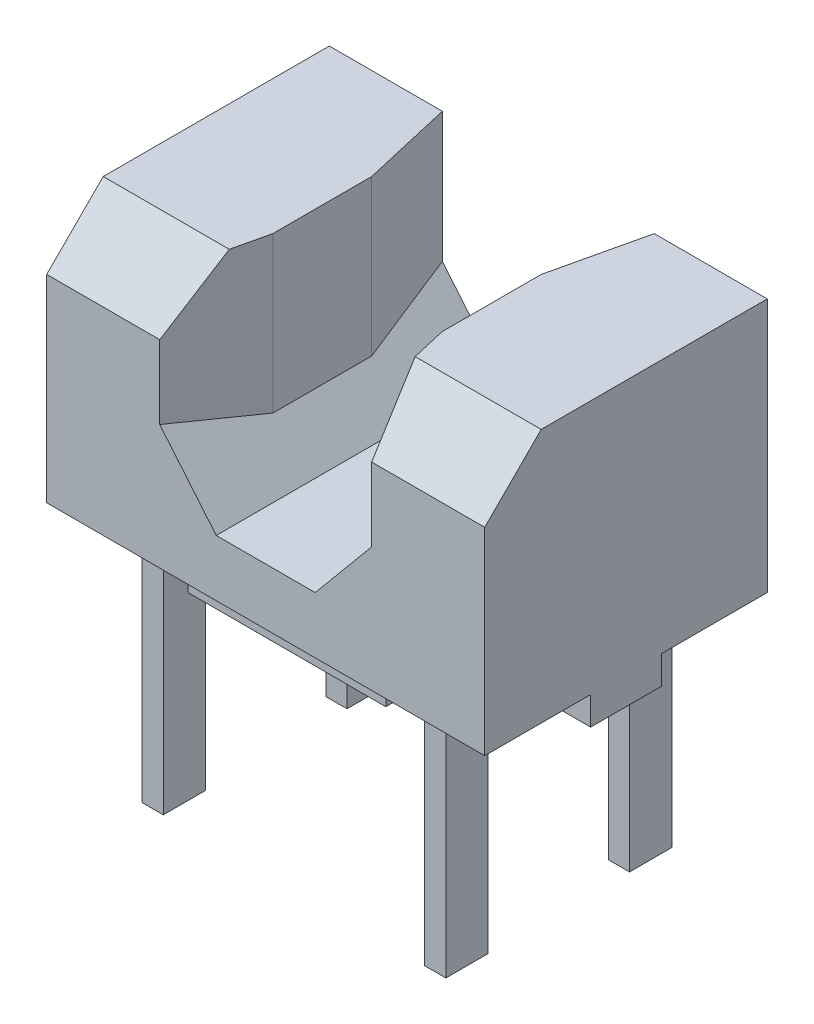
from build123d import *

# Parameters (mm, degrees)
BOSS_EXTRUDE1_DEPTH     = 1
BOSS_EXTRUDE2_START     = -1.1
BOSS_EXTRUDE2_DEPTH     = 1.1
CHAMFER1_SIZE           = 0.4
CUT_EXTRUDE1_DEPTH      = 0.2
SKETCH4_W               = 0.3
SKETCH4_H               = 0.5
CUT_EXTRUDE2_DEPTH      = 0.2
SKETCH5_W               = 0.15
SKETCH5_H               = 0.3
BOSS_EXTRUDE3_DEPTH     = 1.7
MIRROR3_COPY_1_SKETCH_W = 0.15
MIRROR3_COPY_1_SKETCH_H = 0.3
MIRROR3_COPY_1_DEPTH    = 1.7


with BuildPart() as part:
    # Sketch1 → Boss-Extrude1 (new body, symmetric)
    with BuildSketch(Plane.XY):
        Polygon((-0.75, 2), (-0.75, 1.08), (-0.35, 0.6), (0.35, 0.6), (0.75, 1.08), (0.75, 2), (1.55, 2), (1.55, 0), (-1.55, 0), (-1.55, 2), align=None)
    extrude(amount=BOSS_EXTRUDE1_DEPTH, both=True)

    # Sketch2 → Boss-Extrude2 (add)
    with BuildSketch(Plane(origin=(0, 2, 0), x_dir=(1, 0, 0), z_dir=(0, 1, 0)).offset(BOSS_EXTRUDE2_START)):
        Polygon((0.75, 1), (0.6, 0.35), (0.6, -0.35), (0.75, -1), align=None)
    boss_extrude2 = extrude(amount=BOSS_EXTRUDE2_DEPTH)

    # Mirror1: Boss-Extrude2 across plane
    add(boss_extrude2.mirror(Plane(origin=(0, 0, 0), x_dir=(0, 0, 1), z_dir=(1, 0, 0))))

    # Chamfer1
    chamfer1_edges = [part.edges().sort_by_distance(p)[0] for p in [
        (1.15, 2, 1),
        (-1.15, 2, 1),
    ]]
    chamfer(chamfer1_edges, length=CHAMFER1_SIZE)

    # Sketch3 → Cut-Extrude1 (cut)
    with BuildSketch(Plane.XZ):
        Polygon((-0.7, -0.25), (-1.55, -0.25), (-1.55, -1), (1.55, -1), (1.55, -0.25), (0.7, -0.25), (0.7, -0.85), (-0.7, -0.85), align=None)
        Polygon((-1.55, 1), (1.55, 1), (1.55, 0.25), (0.7, 0.25), (0.7, 0.85), (-0.7, 0.85), (-0.7, 0.25), (-1.55, 0.25), align=None)
    extrude(amount=-CUT_EXTRUDE1_DEPTH, mode=Mode.SUBTRACT)

    # Sketch4 → Cut-Extrude2 (cut)
    with BuildSketch(Plane.ZY.offset(-0.6)):
        with Locations((0, 1.6)):
            Rectangle(SKETCH4_W, SKETCH4_H)
    extrude(amount=-CUT_EXTRUDE2_DEPTH, mode=Mode.SUBTRACT)

    # Sketch5 → Boss-Extrude3 (add)
    with BuildSketch(Plane.XZ.offset(-0.2)):
        with Locations((1, -0.65)):
            Rectangle(SKETCH5_W, SKETCH5_H)
    boss_extrude3 = extrude(amount=BOSS_EXTRUDE3_DEPTH)

    # Mirror2: Boss-Extrude3 across plane
    add(boss_extrude3.mirror(Plane.XY))

    # Mirror3: Boss-Extrude3 across plane
    add(boss_extrude3.mirror(Plane(origin=(0, 0, 0), x_dir=(0, 0, 1), z_dir=(1, 0, 0))))

    # Mirror3 copy 1 sketch → Mirror3 copy 1 (add)
    with BuildSketch(Plane(origin=(0, 0.2, 0), x_dir=(-1, 0, 0), z_dir=(0, -1, 0))):
        with Locations((1, -0.65)):
            Rectangle(MIRROR3_COPY_1_SKETCH_W, MIRROR3_COPY_1_SKETCH_H)
    extrude(amount=MIRROR3_COPY_1_DEPTH)


solid = part.part
